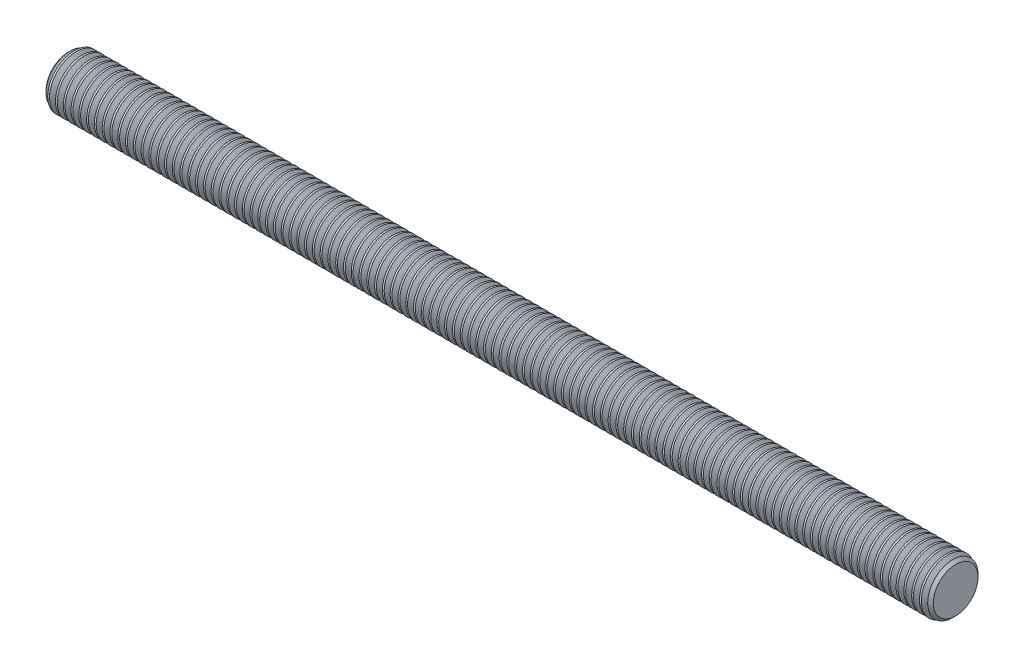
from build123d import *

# Parameters (mm, degrees)
BODYSKE_W       = 200
BODYSKE_H       = 6
CHAMFER1_SIZE   = 0.964
THDSCHPAT_COUNT = 114
THDSCHPAT_PITCH = 1.754385965


with BuildPart() as part:
    # BodySke → BaseBody (revolve)
    with BuildSketch(Plane.XY):
        with Locations((100, 3)):
            Rectangle(BODYSKE_W, BODYSKE_H)
    revolve(axis=Axis((-3.175, 0, 0), (1, 0, 0)))

    # Chamfer1
    chamfer1_edges = [part.edges().sort_by_distance(p)[0] for p in [
        (200, -6, 0),
        (0, -6, 0),
    ]]
    chamfer(chamfer1_edges, length=CHAMFER1_SIZE)

    # ThdSchSke → ThreadSchematic (revolve, cut)
    with BuildSketch(Plane.XY):
        Polygon((0.675000067, -5.036), (0, -6), (0, -7.5), (1.350000134, -7.5), (1.350000134, -6), align=None)
    threadschematic = revolve(axis=Axis((-3.175, 0, 0), (1, 0, 0)), mode=Mode.SUBTRACT)

    # ThdSchPat: ThreadSchematic ×114
    with Locations(*[(i * THDSCHPAT_PITCH, 0, 0) for i in range(1, THDSCHPAT_COUNT)]):
        add(threadschematic, mode=Mode.SUBTRACT)


solid = part.part
